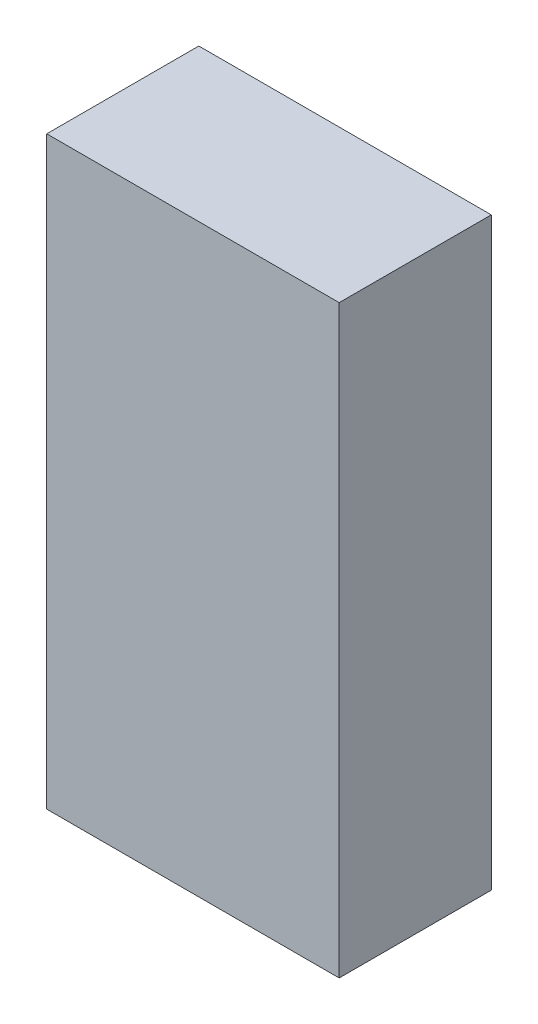
from build123d import *

# Parameters (mm, degrees)
SKETCH2_W           = 5
SKETCH2_H           = 2.6
BOSS_EXTRUDE1_DEPTH = 10


with BuildPart() as part:
    # Sketch2 → Boss-Extrude1 (new body)
    with BuildSketch(Plane(origin=(0, 0, 0), x_dir=(1, 0, 0), z_dir=(0, 1, 0))):
        with Locations((-8.643741367, 14.657329806)):
            Rectangle(SKETCH2_W, SKETCH2_H)
    extrude(amount=BOSS_EXTRUDE1_DEPTH)


solid = part.part
